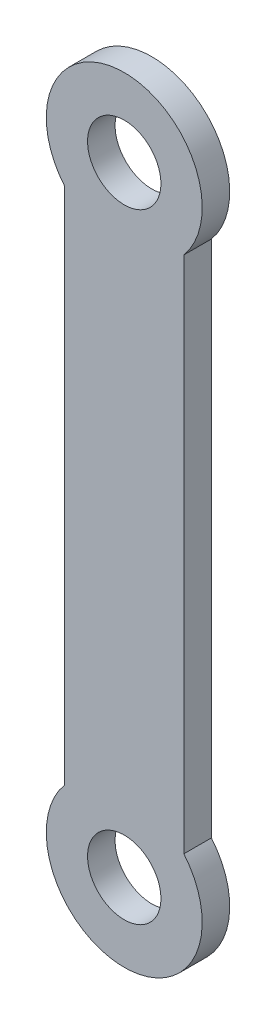
from build123d import *

# Parameters (mm, degrees)
ESQUISSE1_R        = 8
BOSS_EXTRU_1_DEPTH = 6


with BuildPart() as part:
    # Esquisse1 → Boss.-Extru.1 (new body)
    with BuildSketch(Plane.XY):
        with BuildLine():
            Line((13, 10.95445115), (13, 124.04554885))
            ThreePointArc((13, 124.04554885), (0, 152), (-13, 124.04554885))
            Line((-13, 124.04554885), (-13, 10.95445115))
            ThreePointArc((-13, 10.95445115), (0, -17), (13, 10.95445115))
        make_face()
        with Locations((0, 135)):
            Circle(ESQUISSE1_R, mode=Mode.SUBTRACT)
        Circle(ESQUISSE1_R, mode=Mode.SUBTRACT)
    extrude(amount=BOSS_EXTRU_1_DEPTH)


solid = part.part
